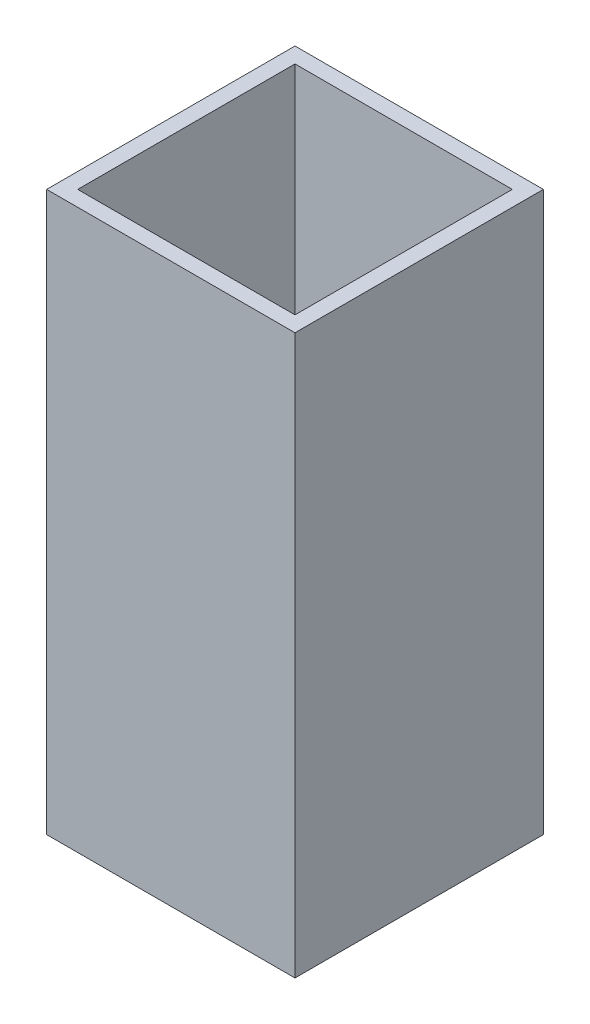
from build123d import *

# Parameters (mm, degrees)
SKETCH1_W           = 50.8
SKETCH1_H           = 50.8
SKETCH1_W_2         = 44.45
SKETCH1_H_2         = 44.45
BOSS_EXTRUDE1_DEPTH = 114.3


with BuildPart() as part:
    # Sketch1 → Boss-Extrude1 (new body)
    with BuildSketch(Plane(origin=(0, 0, 0), x_dir=(1, 0, 0), z_dir=(0, 1, 0))):
        Rectangle(SKETCH1_W, SKETCH1_H)
        Rectangle(SKETCH1_W_2, SKETCH1_H_2, mode=Mode.SUBTRACT)
    extrude(amount=BOSS_EXTRUDE1_DEPTH)


solid = part.part
